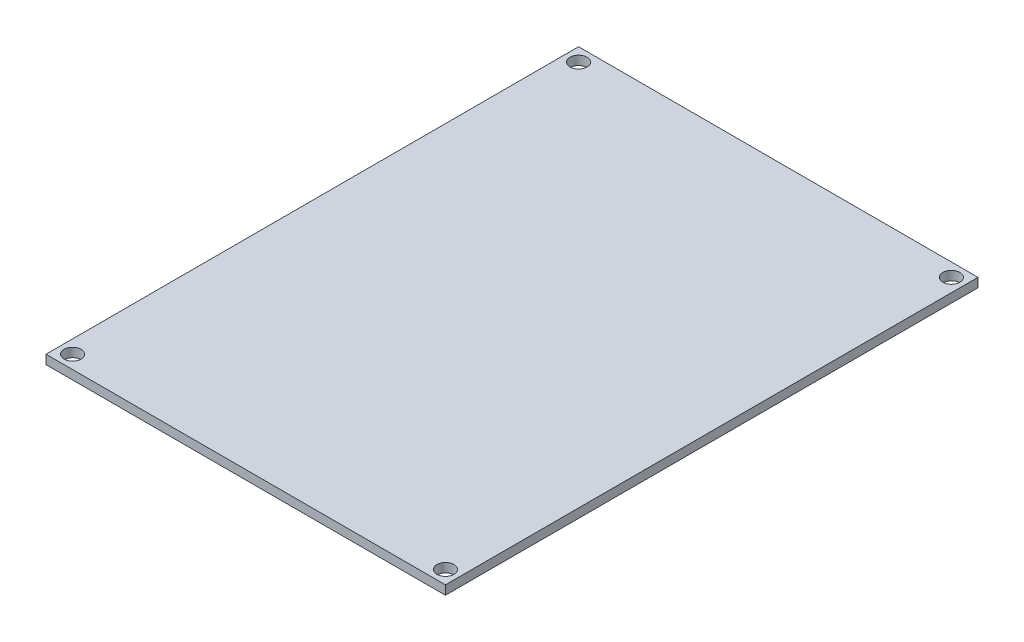
from build123d import *

# Parameters (mm, degrees)
SKETCH1_W           = 75
SKETCH1_H           = 100
BOSS_EXTRUDE1_DEPTH = 1.7
CUT_EXTRUDE1_REACH  = 64.523


with BuildPart() as part:
    # Sketch1 → Boss-Extrude1 (new body)
    with BuildSketch(Plane(origin=(0, 0, 0), x_dir=(1, 0, 0), z_dir=(0, 1, 0))):
        Rectangle(SKETCH1_W, SKETCH1_H)
    extrude(amount=BOSS_EXTRUDE1_DEPTH)

    # Sketch2 → Cut-Extrude1 (cut, up to next)
    with BuildSketch(Plane(origin=(0, 1.7, 0), x_dir=(1, 0, 0), z_dir=(0, 1, 0)), mode=Mode.PRIVATE) as cut_extrude1_sk1:
        with BuildLine():
            ThreePointArc((-33.4, 47.5), (-36.13137085, 48.63137085), (-35, 45.9))
            Line((-35, 45.9), (-35, 47.5))
            Line((-35, 47.5), (-33.4, 47.5))
        make_face()
    cut_extrude1_tool1 = extrude(cut_extrude1_sk1.sketch, amount=-CUT_EXTRUDE1_REACH, mode=Mode.PRIVATE) & part.part
    # Sketch2 → Cut-Extrude1 (cut, up to next)
    with BuildSketch(Plane(origin=(0, 1.7, 0), x_dir=(1, 0, 0), z_dir=(0, 1, 0)), mode=Mode.PRIVATE) as cut_extrude1_sk2:
        with BuildLine():
            Line((-35, 47.5), (-35, 45.9))
            ThreePointArc((-35, 45.9), (-33.86862915, 46.36862915), (-33.4, 47.5))
            Line((-33.4, 47.5), (-35, 47.5))
        make_face()
    cut_extrude1_tool2 = extrude(cut_extrude1_sk2.sketch, amount=-CUT_EXTRUDE1_REACH, mode=Mode.PRIVATE) & part.part
    # Sketch2 → Cut-Extrude1 (cut, up to next)
    with BuildSketch(Plane(origin=(0, 1.7, 0), x_dir=(1, 0, 0), z_dir=(0, 1, 0)), mode=Mode.PRIVATE) as cut_extrude1_sk3:
        with BuildLine():
            ThreePointArc((-33.4, 47.5), (-36.13137085, 48.63137085), (-35, 45.9))
            Line((-35, 45.9), (-35, 47.5))
            Line((-35, 47.5), (-33.4, 47.5))
        make_face()
    cut_extrude1_tool3 = extrude(cut_extrude1_sk3.sketch, amount=-CUT_EXTRUDE1_REACH, mode=Mode.PRIVATE) & part.part
    # Sketch2 → Cut-Extrude1 (cut, up to next)
    with BuildSketch(Plane(origin=(0, 1.7, 0), x_dir=(1, 0, 0), z_dir=(0, 1, 0)), mode=Mode.PRIVATE) as cut_extrude1_sk4:
        with BuildLine():
            Line((-35, 47.5), (-35, 45.9))
            ThreePointArc((-35, 45.9), (-33.86862915, 46.36862915), (-33.4, 47.5))
            Line((-33.4, 47.5), (-35, 47.5))
        make_face()
    cut_extrude1_tool4 = extrude(cut_extrude1_sk4.sketch, amount=-CUT_EXTRUDE1_REACH, mode=Mode.PRIVATE) & part.part
    # Sketch2 → Cut-Extrude1 (cut, up to next)
    with BuildSketch(Plane(origin=(0, 1.7, 0), x_dir=(1, 0, 0), z_dir=(0, 1, 0)), mode=Mode.PRIVATE) as cut_extrude1_sk5:
        with BuildLine():
            ThreePointArc((33.4, 47.5), (33.86862915, 46.36862915), (35, 45.9))
            Line((35, 45.9), (35, 47.5))
            Line((35, 47.5), (33.4, 47.5))
        make_face()
    cut_extrude1_tool5 = extrude(cut_extrude1_sk5.sketch, amount=-CUT_EXTRUDE1_REACH, mode=Mode.PRIVATE) & part.part
    # Sketch2 → Cut-Extrude1 (cut, up to next)
    with BuildSketch(Plane(origin=(0, 1.7, 0), x_dir=(1, 0, 0), z_dir=(0, 1, 0)), mode=Mode.PRIVATE) as cut_extrude1_sk6:
        with BuildLine():
            Line((35, 47.5), (35, 45.9))
            ThreePointArc((35, 45.9), (36.13137085, 46.36862915), (36.6, 47.5))
            ThreePointArc((36.6, 47.5), (35, 49.1), (33.4, 47.5))
            Line((33.4, 47.5), (35, 47.5))
        make_face()
    cut_extrude1_tool6 = extrude(cut_extrude1_sk6.sketch, amount=-CUT_EXTRUDE1_REACH, mode=Mode.PRIVATE) & part.part
    # Sketch2 → Cut-Extrude1 (cut, up to next)
    with BuildSketch(Plane(origin=(0, 1.7, 0), x_dir=(1, 0, 0), z_dir=(0, 1, 0)), mode=Mode.PRIVATE) as cut_extrude1_sk7:
        with BuildLine():
            ThreePointArc((33.4, 47.5), (33.86862915, 46.36862915), (35, 45.9))
            Line((35, 45.9), (35, 47.5))
            Line((35, 47.5), (33.4, 47.5))
        make_face()
    cut_extrude1_tool7 = extrude(cut_extrude1_sk7.sketch, amount=-CUT_EXTRUDE1_REACH, mode=Mode.PRIVATE) & part.part
    # Sketch2 → Cut-Extrude1 (cut, up to next)
    with BuildSketch(Plane(origin=(0, 1.7, 0), x_dir=(1, 0, 0), z_dir=(0, 1, 0)), mode=Mode.PRIVATE) as cut_extrude1_sk8:
        with BuildLine():
            Line((35, 47.5), (35, 45.9))
            ThreePointArc((35, 45.9), (36.13137085, 46.36862915), (36.6, 47.5))
            ThreePointArc((36.6, 47.5), (35, 49.1), (33.4, 47.5))
            Line((33.4, 47.5), (35, 47.5))
        make_face()
    cut_extrude1_tool8 = extrude(cut_extrude1_sk8.sketch, amount=-CUT_EXTRUDE1_REACH, mode=Mode.PRIVATE) & part.part
    # Sketch2 → Cut-Extrude1 (cut, up to next)
    with BuildSketch(Plane(origin=(0, 1.7, 0), x_dir=(1, 0, 0), z_dir=(0, 1, 0)), mode=Mode.PRIVATE) as cut_extrude1_sk9:
        with BuildLine():
            Line((-35, -45.9), (-35, -47.5))
            Line((-35, -47.5), (-33.4, -47.5))
            ThreePointArc((-33.4, -47.5), (-33.86862915, -46.36862915), (-35, -45.9))
        make_face()
    cut_extrude1_tool9 = extrude(cut_extrude1_sk9.sketch, amount=-CUT_EXTRUDE1_REACH, mode=Mode.PRIVATE) & part.part
    # Sketch2 → Cut-Extrude1 (cut, up to next)
    with BuildSketch(Plane(origin=(0, 1.7, 0), x_dir=(1, 0, 0), z_dir=(0, 1, 0)), mode=Mode.PRIVATE) as cut_extrude1_sk10:
        with BuildLine():
            Line((-33.4, -47.5), (-35, -47.5))
            Line((-35, -47.5), (-35, -45.9))
            ThreePointArc((-35, -45.9), (-36.13137085, -48.63137085), (-33.4, -47.5))
        make_face()
    cut_extrude1_tool10 = extrude(cut_extrude1_sk10.sketch, amount=-CUT_EXTRUDE1_REACH, mode=Mode.PRIVATE) & part.part
    # Sketch2 → Cut-Extrude1 (cut, up to next)
    with BuildSketch(Plane(origin=(0, 1.7, 0), x_dir=(1, 0, 0), z_dir=(0, 1, 0)), mode=Mode.PRIVATE) as cut_extrude1_sk11:
        with BuildLine():
            Line((-35, -45.9), (-35, -47.5))
            Line((-35, -47.5), (-33.4, -47.5))
            ThreePointArc((-33.4, -47.5), (-33.86862915, -46.36862915), (-35, -45.9))
        make_face()
    cut_extrude1_tool11 = extrude(cut_extrude1_sk11.sketch, amount=-CUT_EXTRUDE1_REACH, mode=Mode.PRIVATE) & part.part
    # Sketch2 → Cut-Extrude1 (cut, up to next)
    with BuildSketch(Plane(origin=(0, 1.7, 0), x_dir=(1, 0, 0), z_dir=(0, 1, 0)), mode=Mode.PRIVATE) as cut_extrude1_sk12:
        with BuildLine():
            Line((-33.4, -47.5), (-35, -47.5))
            Line((-35, -47.5), (-35, -45.9))
            ThreePointArc((-35, -45.9), (-36.13137085, -48.63137085), (-33.4, -47.5))
        make_face()
    cut_extrude1_tool12 = extrude(cut_extrude1_sk12.sketch, amount=-CUT_EXTRUDE1_REACH, mode=Mode.PRIVATE) & part.part
    # Sketch2 → Cut-Extrude1 (cut, up to next)
    with BuildSketch(Plane(origin=(0, 1.7, 0), x_dir=(1, 0, 0), z_dir=(0, 1, 0)), mode=Mode.PRIVATE) as cut_extrude1_sk13:
        with BuildLine():
            ThreePointArc((35, -45.9), (33.86862915, -46.36862915), (33.4, -47.5))
            Line((33.4, -47.5), (35, -47.5))
            Line((35, -47.5), (35, -45.9))
        make_face()
    cut_extrude1_tool13 = extrude(cut_extrude1_sk13.sketch, amount=-CUT_EXTRUDE1_REACH, mode=Mode.PRIVATE) & part.part
    # Sketch2 → Cut-Extrude1 (cut, up to next)
    with BuildSketch(Plane(origin=(0, 1.7, 0), x_dir=(1, 0, 0), z_dir=(0, 1, 0)), mode=Mode.PRIVATE) as cut_extrude1_sk14:
        with BuildLine():
            Line((35, -47.5), (33.4, -47.5))
            ThreePointArc((33.4, -47.5), (35, -49.1), (36.6, -47.5))
            ThreePointArc((36.6, -47.5), (36.13137085, -46.36862915), (35, -45.9))
            Line((35, -45.9), (35, -47.5))
        make_face()
    cut_extrude1_tool14 = extrude(cut_extrude1_sk14.sketch, amount=-CUT_EXTRUDE1_REACH, mode=Mode.PRIVATE) & part.part
    # Sketch2 → Cut-Extrude1 (cut, up to next)
    with BuildSketch(Plane(origin=(0, 1.7, 0), x_dir=(1, 0, 0), z_dir=(0, 1, 0)), mode=Mode.PRIVATE) as cut_extrude1_sk15:
        with BuildLine():
            ThreePointArc((35, -45.9), (33.86862915, -46.36862915), (33.4, -47.5))
            Line((33.4, -47.5), (35, -47.5))
            Line((35, -47.5), (35, -45.9))
        make_face()
    cut_extrude1_tool15 = extrude(cut_extrude1_sk15.sketch, amount=-CUT_EXTRUDE1_REACH, mode=Mode.PRIVATE) & part.part
    # Sketch2 → Cut-Extrude1 (cut, up to next)
    with BuildSketch(Plane(origin=(0, 1.7, 0), x_dir=(1, 0, 0), z_dir=(0, 1, 0)), mode=Mode.PRIVATE) as cut_extrude1_sk16:
        with BuildLine():
            Line((35, -47.5), (33.4, -47.5))
            ThreePointArc((33.4, -47.5), (35, -49.1), (36.6, -47.5))
            ThreePointArc((36.6, -47.5), (36.13137085, -46.36862915), (35, -45.9))
            Line((35, -45.9), (35, -47.5))
        make_face()
    cut_extrude1_tool16 = extrude(cut_extrude1_sk16.sketch, amount=-CUT_EXTRUDE1_REACH, mode=Mode.PRIVATE) & part.part
    add(cut_extrude1_tool1.solids().sort_by_distance((-35.226354, 1.7, -47.726354))[0], mode=Mode.SUBTRACT)
    add(cut_extrude1_tool2.solids().sort_by_distance((-34.320939, 1.7, -46.820939))[0], mode=Mode.SUBTRACT)
    add(cut_extrude1_tool3.solids().sort_by_distance((-35.226354, 1.7, -47.726354))[0], mode=Mode.SUBTRACT)
    add(cut_extrude1_tool4.solids().sort_by_distance((-34.320939, 1.7, -46.820939))[0], mode=Mode.SUBTRACT)
    add(cut_extrude1_tool5.solids().sort_by_distance((34.320939, 1.7, -46.820939))[0], mode=Mode.SUBTRACT)
    add(cut_extrude1_tool6.solids().sort_by_distance((35.226354, 1.7, -47.726354))[0], mode=Mode.SUBTRACT)
    add(cut_extrude1_tool7.solids().sort_by_distance((34.320939, 1.7, -46.820939))[0], mode=Mode.SUBTRACT)
    add(cut_extrude1_tool8.solids().sort_by_distance((35.226354, 1.7, -47.726354))[0], mode=Mode.SUBTRACT)
    add(cut_extrude1_tool9.solids().sort_by_distance((-34.320939, 1.7, 46.820939))[0], mode=Mode.SUBTRACT)
    add(cut_extrude1_tool10.solids().sort_by_distance((-35.226354, 1.7, 47.726354))[0], mode=Mode.SUBTRACT)
    add(cut_extrude1_tool11.solids().sort_by_distance((-34.320939, 1.7, 46.820939))[0], mode=Mode.SUBTRACT)
    add(cut_extrude1_tool12.solids().sort_by_distance((-35.226354, 1.7, 47.726354))[0], mode=Mode.SUBTRACT)
    add(cut_extrude1_tool13.solids().sort_by_distance((34.320939, 1.7, 46.820939))[0], mode=Mode.SUBTRACT)
    add(cut_extrude1_tool14.solids().sort_by_distance((35.226354, 1.7, 47.726354))[0], mode=Mode.SUBTRACT)
    add(cut_extrude1_tool15.solids().sort_by_distance((34.320939, 1.7, 46.820939))[0], mode=Mode.SUBTRACT)
    add(cut_extrude1_tool16.solids().sort_by_distance((35.226354, 1.7, 47.726354))[0], mode=Mode.SUBTRACT)


solid = part.part
